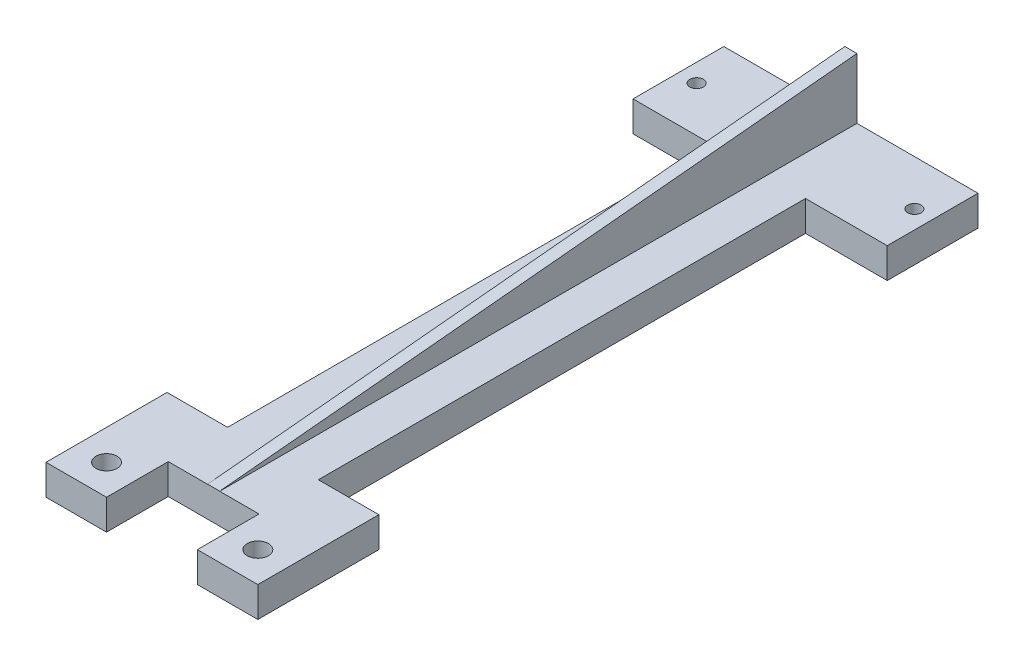
from build123d import *

# Parameters (mm, degrees)
SKETCH1_W           = 42
SKETCH1_H           = 15
BOSS_EXTRUDE1_DEPTH = 5
SKETCH2_R           = 1.115
CUT_EXTRUDE1_DEPTH  = 6
SKETCH3_W           = 15
SKETCH3_H           = 80.5
BOSS_EXTRUDE2_DEPTH = 5
SKETCH4_W           = 35
SKETCH4_H           = 10
BOSS_EXTRUDE3_DEPTH = 5
SKETCH5_W           = 10
SKETCH5_H           = 10
BOSS_EXTRUDE4_DEPTH = 5
SKETCH6_R           = 1.75
CUT_EXTRUDE2_DEPTH  = 6
SKETCH7_W           = 15
SKETCH7_H           = 0.2
CUT_EXTRUDE3_DEPTH  = 6
SKETCH8_W           = 2
SKETCH8_H           = 105.3
BOSS_EXTRUDE5_DEPTH = 10
CUT_EXTRUDE4_DEPTH  = 23


with BuildPart() as part:
    # Sketch1 → Boss-Extrude1 (new body)
    with BuildSketch(Plane(origin=(0, 0, 0), x_dir=(1, 0, 0), z_dir=(0, 1, 0))):
        with Locations((21, 7.5)):
            Rectangle(SKETCH1_W, SKETCH1_H)
    extrude(amount=BOSS_EXTRUDE1_DEPTH)

    # Sketch2 → Cut-Extrude1 (cut, through all)
    with BuildSketch(Plane(origin=(0, 5, 0), x_dir=(1, 0, 0), z_dir=(0, 1, 0))):
        with Locations((3, 7.5)):
            Circle(SKETCH2_R)
        with Locations((39, 7.5)):
            Circle(SKETCH2_R)
    extrude(amount=-CUT_EXTRUDE1_DEPTH, mode=Mode.SUBTRACT)

    # Sketch3 → Boss-Extrude2 (add)
    with BuildSketch(Plane(origin=(0, 5, 0), x_dir=(1, 0, 0), z_dir=(0, 1, 0))):
        with Locations((21, -40.25)):
            Rectangle(SKETCH3_W, SKETCH3_H)
    extrude(amount=-BOSS_EXTRUDE2_DEPTH)

    # Sketch4 → Boss-Extrude3 (add)
    with BuildSketch(Plane(origin=(0, 5, 0), x_dir=(1, 0, 0), z_dir=(0, 1, 0))):
        with Locations((21, -85.5)):
            Rectangle(SKETCH4_W, SKETCH4_H)
    extrude(amount=-BOSS_EXTRUDE3_DEPTH)

    # Sketch5 → Boss-Extrude4 (add)
    with BuildSketch(Plane(origin=(0, 5, 0), x_dir=(1, 0, 0), z_dir=(0, 1, 0))):
        with Locations((8.5, -95.5)):
            Rectangle(SKETCH5_W, SKETCH5_H)
        with Locations((33.5, -95.5)):
            Rectangle(SKETCH5_W, SKETCH5_H)
    extrude(amount=-BOSS_EXTRUDE4_DEPTH)

    # Sketch6 → Cut-Extrude2 (cut, through all)
    with BuildSketch(Plane(origin=(0, 5, 0), x_dir=(1, 0, 0), z_dir=(0, 1, 0))):
        with Locations((8.5, -95.5)):
            Circle(SKETCH6_R)
        with Locations((33.5, -95.5)):
            Circle(SKETCH6_R)
    extrude(amount=-CUT_EXTRUDE2_DEPTH, mode=Mode.SUBTRACT)

    # Sketch7 → Cut-Extrude3 (cut, through all)
    with BuildSketch(Plane(origin=(0, 5, 0), x_dir=(1, 0, 0), z_dir=(0, 1, 0))):
        with Locations((21, -90.4)):
            Rectangle(SKETCH7_W, SKETCH7_H)
    extrude(amount=-CUT_EXTRUDE3_DEPTH, mode=Mode.SUBTRACT)

    # Sketch8 → Boss-Extrude5 (add)
    with BuildSketch(Plane(origin=(0, 5, 0), x_dir=(1, 0, 0), z_dir=(0, 1, 0))):
        with Locations((21, -37.65)):
            Rectangle(SKETCH8_W, SKETCH8_H)
    extrude(amount=BOSS_EXTRUDE5_DEPTH)

    # Sketch9 → Cut-Extrude4 (cut, through all)
    with BuildSketch(Plane.ZY.offset(-20)):
        Polygon((-15, 15), (90.5, 5), (90.3, 15), align=None)
    extrude(amount=-CUT_EXTRUDE4_DEPTH, mode=Mode.SUBTRACT)


solid = part.part
